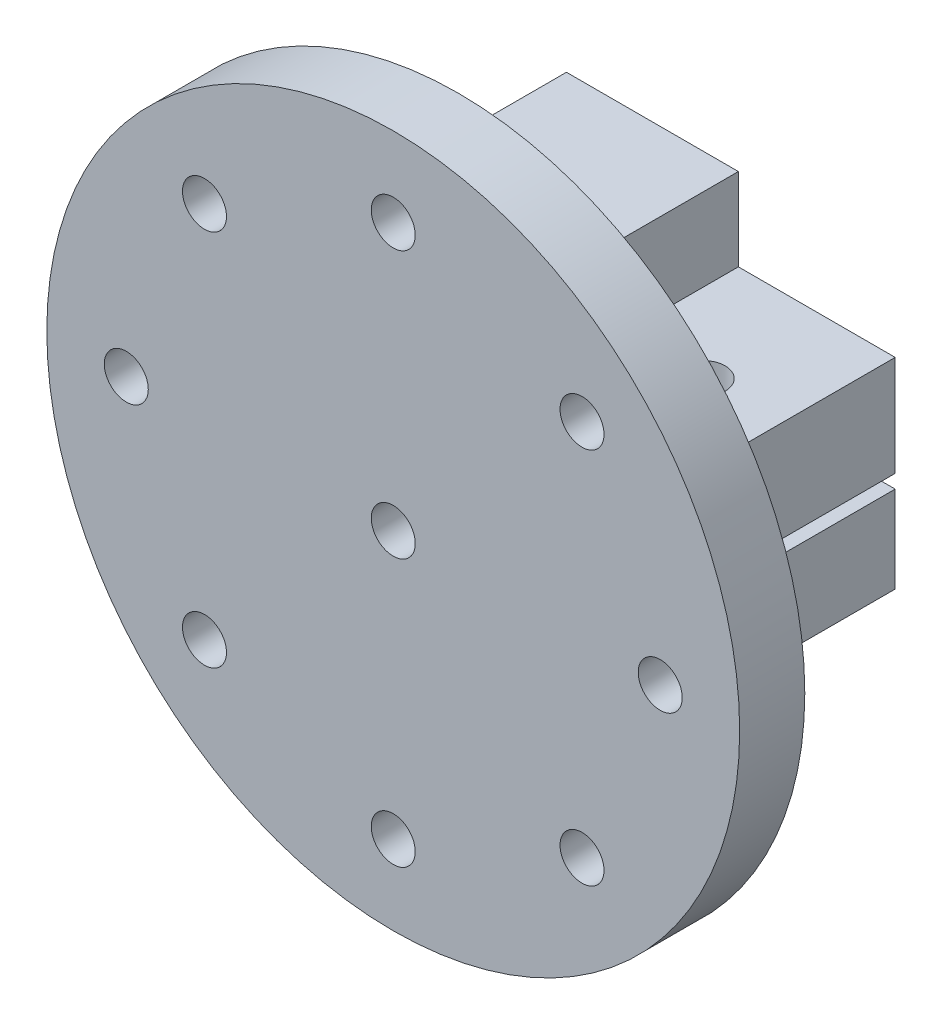
from build123d import *

# Parameters (mm, degrees)
SKETCH_1_W           = 30
SKETCH_1_H           = 14.828427124
EXTRUDE_2_DEPTH      = 33
CUT_EXTRUDE_9_DEPTH  = 46
CUT_EXTRUDE_10_DEPTH = 30
CUT_EXTRUDE_12_DEPTH = 40
CUT_EXTRUDE_13_DEPTH = 46
CUT_EXTRUDE_18_DEPTH = 285
SKETCH_12_R          = 50
EXTRUDE_7_DEPTH      = 9.398
SKETCH_12_5_R        = 3.175
CUT_EXTRUDE_27_DEPTH = 63
SKETCH_20_R          = 6
SKETCH_20_R_2        = 3.175
EXTRUDE_9_DEPTH      = 3
SKETCH_1_26_W        = 11
SKETCH_1_26_H        = 2
CUT_EXTRUDE_29_DEPTH = 31
SKETCH_1_27_W        = 11
SKETCH_1_27_H        = 2
CUT_EXTRUDE_30_DEPTH = 33
CUT_EXTRUDE_31_DEPTH = 33
CUT_EXTRUDE_32_DEPTH = 33
SKETCH_21_R          = 6
SKETCH_21_R_2        = 3.175
EXTRUDE_11_DEPTH     = 34
SKETCH_21_5_R        = 6
SKETCH_21_5_R_2      = 3.175
CUT_EXTRUDE_34_DEPTH = 31
SKETCH_22_R          = 3.175
CUT_EXTRUDE_35_DEPTH = 31
SKETCH_24_W          = 25
SKETCH_24_H          = 20
EXTRUDE_12_DEPTH     = 33
EXTRUDE_13_DEPTH     = 34
SKETCH_25_W          = 9.1968428
SKETCH_25_H          = 2.038804585
SKETCH_25_H_2        = 2
EXTRUDE_14_DEPTH     = 33
EXTRUDE_15_DEPTH     = 36
SKETCH_28_W          = 22.632732516
SKETCH_28_H          = 2.5
SKETCH_28_W_2        = 22.447864345
CUT_EXTRUDE_43_DEPTH = 33
SKETCH_1_32_W        = 0.7
SKETCH_1_32_H        = 1
CUT_EXTRUDE_45_DEPTH = 33
SKETCH_27_R          = 3.175
CUT_EXTRUDE_46_DEPTH = 70


with BuildPart() as part:
    # 草图1 → 凸台-拉伸2 (new body)
    with BuildSketch(Plane.XY):
        with Locations((7.585786438, 0)):
            Rectangle(SKETCH_1_W, SKETCH_1_H)
    extrude(amount=EXTRUDE_2_DEPTH)

    # 草图1<11> → 切除-拉伸9 (cut)
    with BuildSketch(Plane.XY):
        with BuildLine():
            Line((0, -2), (0, 0))
            Line((0, 0), (-6, 0))
            ThreePointArc((-6, 0), (-4.242640687, -4.242640687), (0, -6))
            ThreePointArc((0, -6), (3.464101615, -4.898979486), (5.656854249, -2))
            Line((5.656854249, -2), (0, -2))
        make_face()
    extrude(amount=CUT_EXTRUDE_9_DEPTH, mode=Mode.SUBTRACT)

    # 草图1<12> → 切除-拉伸10 (cut)
    with BuildSketch(Plane.XY):
        with BuildLine():
            Line((-6, 0), (0, 0))
            Line((0, 0), (0, 2))
            Line((0, 2), (0, 6))
            ThreePointArc((0, 6), (-4.242640687, 4.242640687), (-6, 0))
        make_face()
    extrude(amount=CUT_EXTRUDE_10_DEPTH, mode=Mode.SUBTRACT)

    # 草图1<14> → 切除-拉伸12 (cut)
    with BuildSketch(Plane.XY):
        with BuildLine():
            Line((6, 0), (0, 0))
            Line((0, 0), (0, -2))
            Line((0, -2), (5.656854249, -2))
            ThreePointArc((5.656854249, -2), (5.913591358, -1.014611872), (6, 0))
        make_face()
    extrude(amount=CUT_EXTRUDE_12_DEPTH, mode=Mode.SUBTRACT)

    # 草图1<15> → 切除-拉伸13 (cut)
    with BuildSketch(Plane.XY):
        with BuildLine():
            Line((0, 6), (0, 2))
            Line((0, 2), (5.656854249, 2))
            ThreePointArc((5.656854249, 2), (3.464101615, 4.898979486), (0, 6))
        make_face()
    extrude(amount=CUT_EXTRUDE_13_DEPTH, mode=Mode.SUBTRACT)

    # 草图1<20> → 切除-拉伸18 (cut)
    with BuildSketch(Plane.XY):
        with BuildLine():
            ThreePointArc((7.414213562, 7.414213562), (9.005239827, 5.370919954), (10.046946078, 3))
            Line((10.046946078, 3), (18, 3))
            Line((18, 3), (20.850103278, 3))
            Line((20.850103278, 3), (20.850103278, 1))
            Line((20.850103278, 1), (18, 1))
            Line((18, 1), (18, -1))
            Line((18, -1), (20.850103278, -1))
            Line((20.850103278, -1), (20.850103278, -3))
            Line((20.850103278, -3), (18, -3))
            Line((18, -3), (10.046946078, -3))
            ThreePointArc((10.046946078, -3), (9.005239827, -5.370919954), (7.414213562, -7.414213562))
            Line((7.414213562, -7.414213562), (22.585786438, -7.414213562))
            Line((22.585786438, -7.414213562), (22.585786438, 7.414213562))
            Line((22.585786438, 7.414213562), (7.414213562, 7.414213562))
        make_face()
    extrude(amount=CUT_EXTRUDE_18_DEPTH, mode=Mode.SUBTRACT)

    # 草图12 → 凸台-拉伸7 (add)
    with BuildSketch(Plane.XY.offset(33)):
        Circle(SKETCH_12_R)
    extrude(amount=EXTRUDE_7_DEPTH)

    # 草图12<5> → 切除-拉伸27 (cut)
    with BuildSketch(Plane.XY.offset(33)):
        with Locations((0, 38.530339059)):
            Circle(SKETCH_12_5_R)
        with Locations((-27.24506403, 27.24506403)):
            Circle(SKETCH_12_5_R)
        with Locations((27.24506403, -27.24506403)):
            Circle(SKETCH_12_5_R)
        with Locations((-38.530339059, 0)):
            Circle(SKETCH_12_5_R)
        with Locations((38.530339059, 0)):
            Circle(SKETCH_12_5_R)
        with Locations((0, -38.530339059)):
            Circle(SKETCH_12_5_R)
        with Locations((-27.24506403, -27.24506403)):
            Circle(SKETCH_12_5_R)
        with Locations((27.24506403, 27.24506403)):
            Circle(SKETCH_12_5_R)
    extrude(amount=CUT_EXTRUDE_27_DEPTH, mode=Mode.SUBTRACT)

    # 草图20 → 凸台-拉伸9 (add)
    with BuildSketch(Plane(origin=(0, 0, 0), x_dir=(-1, 0, 0), z_dir=(0, 0, -1))):
        Circle(SKETCH_20_R)
        Circle(SKETCH_20_R_2, mode=Mode.SUBTRACT)
    extrude(amount=-EXTRUDE_9_DEPTH)

    # 草图1<26> → 切除-拉伸29 (cut)
    with BuildSketch(Plane.XY):
        with Locations((12.5, 0)):
            Rectangle(SKETCH_1_26_W, SKETCH_1_26_H)
    extrude(amount=CUT_EXTRUDE_29_DEPTH, mode=Mode.SUBTRACT)

    # 草图1<27> → 切除-拉伸30 (cut)
    with BuildSketch(Plane.XY):
        with BuildLine():
            Line((0, 2), (0, 0))
            Line((0, 0), (6, 0))
            ThreePointArc((6, 0), (5.913591358, 1.014611872), (5.656854249, 2))
            Line((5.656854249, 2), (0, 2))
        make_face()
        with Locations((12.5, 0)):
            Rectangle(SKETCH_1_27_W, SKETCH_1_27_H)
    extrude(amount=CUT_EXTRUDE_30_DEPTH, mode=Mode.SUBTRACT)

    # 草图1<28> → 切除-拉伸31 (cut)
    with BuildSketch(Plane.XY):
        with BuildLine():
            Line((6, 0), (0, 0))
            Line((0, 0), (0, -2))
            Line((0, -2), (7, -2))
            Line((7, -2), (7, 2))
            Line((7, 2), (5.656854249, 2))
            ThreePointArc((5.656854249, 2), (5.913591358, 1.014611872), (6, 0))
        make_face()
        with BuildLine():
            Line((-6, 0), (0, 0))
            Line((0, 0), (0, 6))
            ThreePointArc((0, 6), (-4.242640687, 4.242640687), (-6, 0))
        make_face()
    extrude(amount=CUT_EXTRUDE_31_DEPTH, mode=Mode.SUBTRACT)

    # 草图1<29> → 切除-拉伸32 (cut)
    with BuildSketch(Plane.XY):
        with BuildLine():
            Line((0, -2), (0, 0))
            Line((0, 0), (-6, 0))
            ThreePointArc((-6, 0), (-1.014611872, -5.913591358), (5.656854249, -2))
            Line((5.656854249, -2), (0, -2))
        make_face()
        with BuildLine():
            Line((0, 6), (0, 2))
            Line((0, 2), (5.656854249, 2))
            ThreePointArc((5.656854249, 2), (3.464101615, 4.898979486), (0, 6))
        make_face()
    extrude(amount=CUT_EXTRUDE_32_DEPTH, mode=Mode.SUBTRACT)

    # 草图21 → 凸台-拉伸11 (add)
    with BuildSketch(Plane(origin=(0, 0, 0), x_dir=(-1, 0, 0), z_dir=(0, 0, -1))):
        Circle(SKETCH_21_R)
        Circle(SKETCH_21_R_2, mode=Mode.SUBTRACT)
    extrude(amount=-EXTRUDE_11_DEPTH)

    # 草图21<5> → 切除-拉伸34 (cut)
    with BuildSketch(Plane(origin=(0, 0, 0), x_dir=(-1, 0, 0), z_dir=(0, 0, -1))):
        Circle(SKETCH_21_5_R)
        Circle(SKETCH_21_5_R_2, mode=Mode.SUBTRACT)
    extrude(amount=-CUT_EXTRUDE_34_DEPTH, mode=Mode.SUBTRACT)

    # 草图22 → 切除-拉伸35 (cut)
    with BuildSketch(Plane(origin=(0, 0, 33), x_dir=(-1, 0, 0), z_dir=(0, 0, -1))):
        Circle(SKETCH_22_R)
    extrude(amount=-CUT_EXTRUDE_35_DEPTH, mode=Mode.SUBTRACT)

    # 草图24 → 凸台-拉伸12 (add)
    with BuildSketch(Plane(origin=(0, 0, 0), x_dir=(-1, 0, 0), z_dir=(0, 0, -1))):
        with Locations((4.900918267, -16.64791006)):
            Rectangle(SKETCH_24_W, SKETCH_24_H)
    extrude(amount=-EXTRUDE_12_DEPTH)

    # 草图24<3> → 凸台-拉伸13 (add)
    with BuildSketch(Plane(origin=(0, 0, 0), x_dir=(-1, 0, 0), z_dir=(0, 0, -1))):
        Polygon((-7.414213562, 27.414213562), (-7.414213562, 7.414213562), (7.414213562, 7.414213562), (7.414213562, -6.64791006), (17.400918267, -6.64791006), (17.400918267, 27.414213562), align=None)
    extrude(amount=-EXTRUDE_13_DEPTH)

    # 草图25 → 凸台-拉伸14 (add)
    with BuildSketch(Plane(origin=(0, 0, 0), x_dir=(-1, 0, 0), z_dir=(0, 0, -1))):
        with Locations((-25.448524678, -1.980597708)):
            Rectangle(SKETCH_25_W, SKETCH_25_H)
        with Locations((-25.448524678, 2)):
            Rectangle(SKETCH_25_W, SKETCH_25_H_2)
    extrude(amount=-EXTRUDE_14_DEPTH)

    # 草图26 → 凸台-拉伸15 (add)
    with BuildSketch(Plane(origin=(0, 0, 0), x_dir=(-1, 0, 0), z_dir=(0, 0, -1))):
        with BuildLine():
            Line((-10.046946078, -3), (-30.046946078, -3))
            Line((-30.046946078, -3), (-30.046946078, -15.961195415))
            Line((-30.046946078, -15.961195415), (-7.599081733, -15.961195415))
            Line((-7.599081733, -15.961195415), (-7.599081733, -7.224616412))
            ThreePointArc((-7.599081733, -7.224616412), (-9.072343707, -5.256777069), (-10.046946078, -3))
        make_face()
        with BuildLine():
            Line((-30.046946078, 18), (-30.046946078, 3))
            Line((-30.046946078, 3), (-10.046946078, 3))
            ThreePointArc((-10.046946078, 3), (-9.005239827, 5.370919954), (-7.414213562, 7.414213562))
            Line((-7.414213562, 7.414213562), (-7.414213562, 18))
            Line((-7.414213562, 18), (-30.046946078, 18))
        make_face()
    extrude(amount=-EXTRUDE_15_DEPTH)

    # 草图28 → 切除-拉伸43 (cut)
    with BuildSketch(Plane(origin=(0, 0, 0), x_dir=(-1, 0, 0), z_dir=(0, 0, -1))):
        with Locations((-18.73057982, 16.75)):
            Rectangle(SKETCH_28_W, SKETCH_28_H)
        with Locations((-18.823013906, -14.711195415)):
            Rectangle(SKETCH_28_W_2, SKETCH_28_H)
    extrude(amount=-CUT_EXTRUDE_43_DEPTH, mode=Mode.SUBTRACT)

    # 草图1<32> → 切除-拉伸45 (cut)
    with BuildSketch(Plane.XY):
        with Locations((7.35, -1.5)):
            Rectangle(SKETCH_1_32_W, SKETCH_1_32_H)
        with Locations((7.35, 1.5)):
            Rectangle(SKETCH_1_32_W, SKETCH_1_32_H)
    extrude(amount=CUT_EXTRUDE_45_DEPTH, mode=Mode.SUBTRACT)

    # 草图27 → 切除-拉伸46 (cut)
    with BuildSketch(Plane.XZ.offset(15.961195415)):
        with Locations((18.823013906, 16.5)):
            Circle(SKETCH_27_R)
    extrude(amount=-CUT_EXTRUDE_46_DEPTH, mode=Mode.SUBTRACT)


solid = part.part
